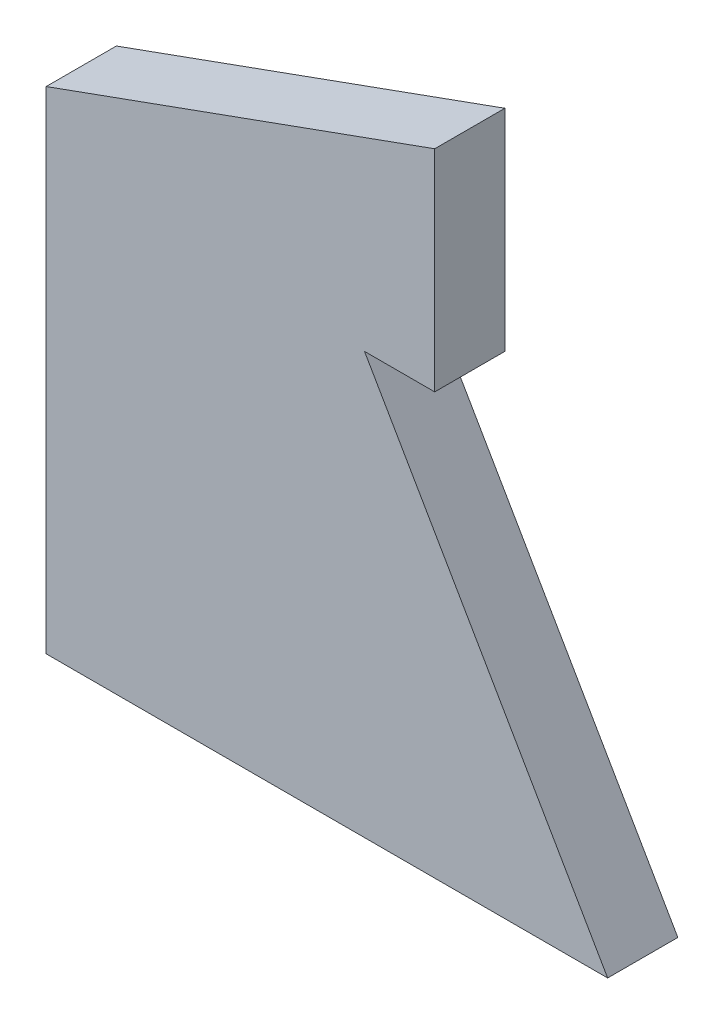
from build123d import *

# Parameters (mm, degrees)
P_IDAT_VYSUNUT_M1_DEPTH = 10


with BuildPart() as part:
    # Skica1 → Přidat vysunutím1 (new body)
    with BuildSketch(Plane.XY):
        Polygon((0, 0), (80, 0), (45.358983849, 60), (55.358983849, 60), (55.358983849, 90), (0, 70), align=None)
    extrude(amount=P_IDAT_VYSUNUT_M1_DEPTH)


solid = part.part
